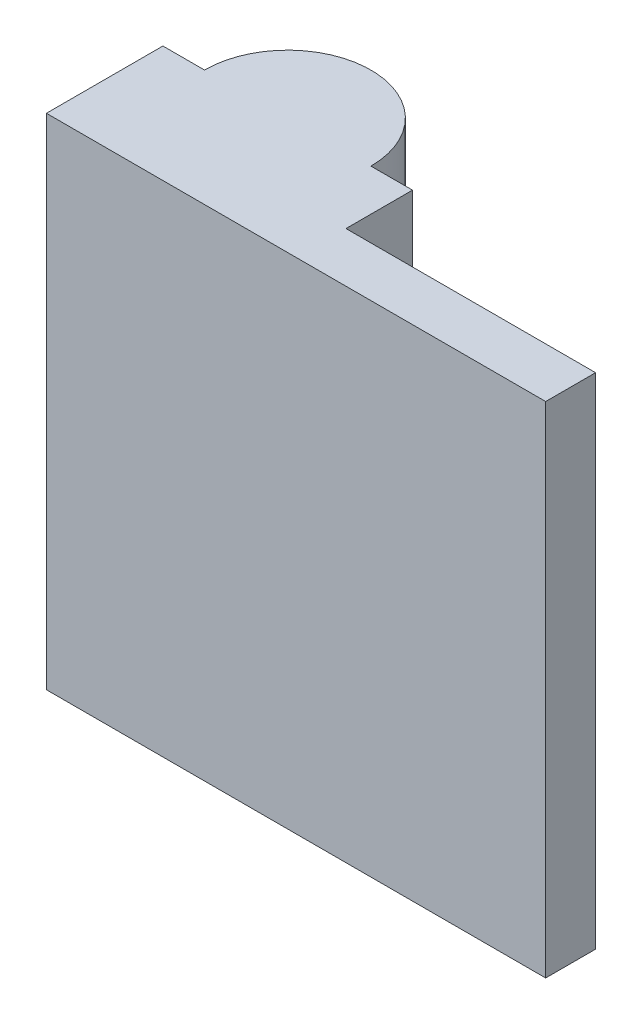
from build123d import *

# Parameters (mm, degrees)
SKETCH1_W               = 30
SKETCH1_H               = 30
BOSS_EXTRUDE1_DEPTH     = 10
SKETCH2_W               = 15
SKETCH2_H               = 30
CUT_EXTRUDE1_DEPTH      = 4
SKETCH4_R               = 1.75
CUT_EXTRUDE3_DEPTH      = 30
SKETCH7_R               = 5
BOSS_EXTRUDE2_DEPTH     = 40
SKETCH8_R               = 3.5
CUT_EXTRUDE4_DEPTH      = 30
SKETCH9_W               = 3
SKETCH9_H               = 30
CUT_EXTRUDE5_DEPTH      = 31
SKETCH11_W              = 33.170745935
SKETCH11_H              = 13.10963014
CUT_EXTRUDE6_DEPTH      = 6
CUT_EXTRUDE6_DEPTH_BACK = 8
SKETCH12_R              = 3.5
BOSS_EXTRUDE3_DEPTH     = 10
BOSS_EXTRUDE4_DEPTH     = 3


with BuildPart() as part:
    # Sketch1 → Boss-Extrude1 (new body)
    with BuildSketch(Plane.XY):
        with Locations((15, 15)):
            Rectangle(SKETCH1_W, SKETCH1_H)
    extrude(amount=BOSS_EXTRUDE1_DEPTH)

    # Sketch2 → Cut-Extrude1 (cut)
    with BuildSketch(Plane(origin=(0, 0, 0), x_dir=(-1, 0, 0), z_dir=(0, 0, -1))):
        with Locations((-22.5, 15)):
            Rectangle(SKETCH2_W, SKETCH2_H)
    extrude(amount=-CUT_EXTRUDE1_DEPTH, mode=Mode.SUBTRACT)

    # Sketch4 → Cut-Extrude3 (cut)
    with BuildSketch(Plane(origin=(0, 0, 4), x_dir=(-1, 0, 0), z_dir=(0, 0, -1))):
        with Locations((-22.5, 0)):
            Circle(SKETCH4_R)
        with Locations((-22.5, 30)):
            Circle(SKETCH4_R)
    extrude(amount=-CUT_EXTRUDE3_DEPTH, mode=Mode.SUBTRACT)

    # Sketch7 → Boss-Extrude2 (add)
    with BuildSketch(Plane.XZ):
        with Locations((7.5, 0)):
            Circle(SKETCH7_R)
    extrude(amount=-BOSS_EXTRUDE2_DEPTH)

    # Sketch8 → Cut-Extrude4 (cut)
    with BuildSketch(Plane.XZ):
        with Locations((7.5, 0)):
            Circle(SKETCH8_R)
    extrude(amount=-CUT_EXTRUDE4_DEPTH, mode=Mode.SUBTRACT)

    # Sketch9 → Cut-Extrude5 (cut, through all)
    with BuildSketch(Plane.ZY):
        with Locations((8.5, 15)):
            Rectangle(SKETCH9_W, SKETCH9_H)
    extrude(amount=-CUT_EXTRUDE5_DEPTH, mode=Mode.SUBTRACT)

    # Sketch11 → Cut-Extrude6 (cut, two sides)
    with BuildSketch(Plane(origin=(0, 0, 0), x_dir=(-1, 0, 0), z_dir=(0, 0, -1))) as cut_extrude6_sk:
        with Locations((-15.51660734, 36.55481507)):
            Rectangle(SKETCH11_W, SKETCH11_H)
    extrude(amount=CUT_EXTRUDE6_DEPTH, mode=Mode.SUBTRACT)
    extrude(cut_extrude6_sk.sketch, amount=-CUT_EXTRUDE6_DEPTH_BACK, mode=Mode.SUBTRACT)

    # Sketch12 → Boss-Extrude3 (add)
    with BuildSketch(Plane(origin=(0, 30, 0), x_dir=(1, 0, 0), z_dir=(0, 1, 0))):
        with Locations((7.5, 0)):
            Circle(SKETCH12_R)
    extrude(amount=-BOSS_EXTRUDE3_DEPTH)

    # Sketch13 → Boss-Extrude4 (add)
    with BuildSketch(Plane(origin=(0, 0, 4), x_dir=(-1, 0, 0), z_dir=(0, 0, -1))):
        with BuildLine():
            Line((-24.25, 30), (-20.75, 30))
            ThreePointArc((-20.75, 30), (-22.5, 28.25), (-24.25, 30))
        make_face()
        with BuildLine():
            Line((-24.25, 0), (-20.75, 0))
            ThreePointArc((-20.75, 0), (-22.5, 1.75), (-24.25, 0))
        make_face()
    extrude(amount=-BOSS_EXTRUDE4_DEPTH)


solid = part.part
